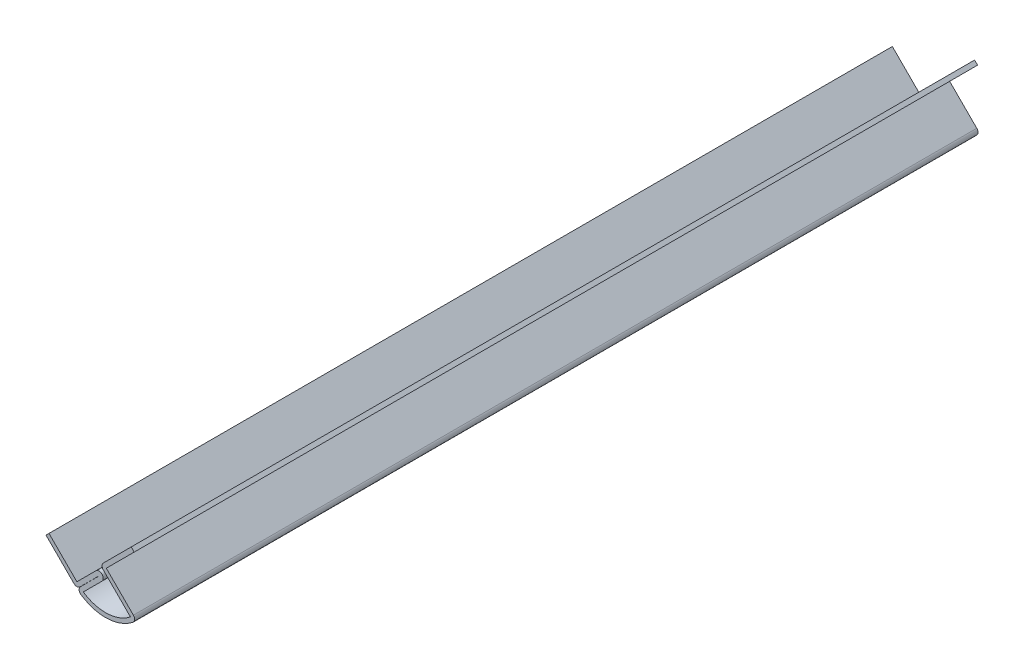
from build123d import *

# Parameters (mm, degrees)
BOSS_EXTRUDE1_DEPTH = 203.5175
FILLET1_R           = 1.016


with BuildPart() as part:
    # Sketch2 → Boss-Extrude1 (new body)
    with BuildSketch(Plane.XY):
        with BuildLine():
            Line((-6.735192091, -6.735192091), (-13.470384182, 0))
            Line((-13.470384182, 0), (-14.188804671, -0.71842049))
            Line((-14.188804671, -0.71842049), (-6.735192091, -8.17203307))
            Line((-6.735192091, -8.17203307), (-1.412145275, -2.848986254))
            ThreePointArc((-1.412145275, -2.848986254), (-1.394184763, -2.848986254), (-1.394184763, -2.866946767))
            Line((-1.394184763, -2.866946767), (-6.717231579, -8.189993582))
            ThreePointArc((-6.717231579, -8.189993582), (0.574505978, -10.754978809), (7.655668343, -7.655668343))
            Line((7.655668343, -7.655668343), (0.359210245, -0.359210245))
            Line((0.359210245, -0.359210245), (7.094402336, 6.375981846))
            Line((7.094402336, 6.375981846), (6.375981846, 7.094402336))
            Line((6.375981846, 7.094402336), (-1.077630735, -0.359210245))
            Line((-1.077630735, -0.359210245), (6.182455958, -7.619296938))
            ThreePointArc((6.182455958, -7.619296938), (0.578453997, -9.738038748), (-5.182039359, -8.091642343))
            Line((-5.182039359, -8.091642343), (-0.675764273, -3.585367256))
            ThreePointArc((-0.675764273, -3.585367256), (-0.675764273, -2.130565765), (-2.130565765, -2.130565765))
            Line((-2.130565765, -2.130565765), (-6.735192091, -6.735192091))
        make_face()
    extrude(amount=-BOSS_EXTRUDE1_DEPTH)

    # Fillet1
    fillet1_edges = [part.edges().sort_by_distance(p)[0] for p in [
        (-1.077630735, -0.359210245, -101.75875),
        (7.655668343, -7.655668343, -101.75875),
        (-6.717231579, -8.189993582, -101.75875),
        (-6.735192091, -8.17203307, -101.75875),
    ]]
    fillet(fillet1_edges, radius=FILLET1_R)


solid = part.part
